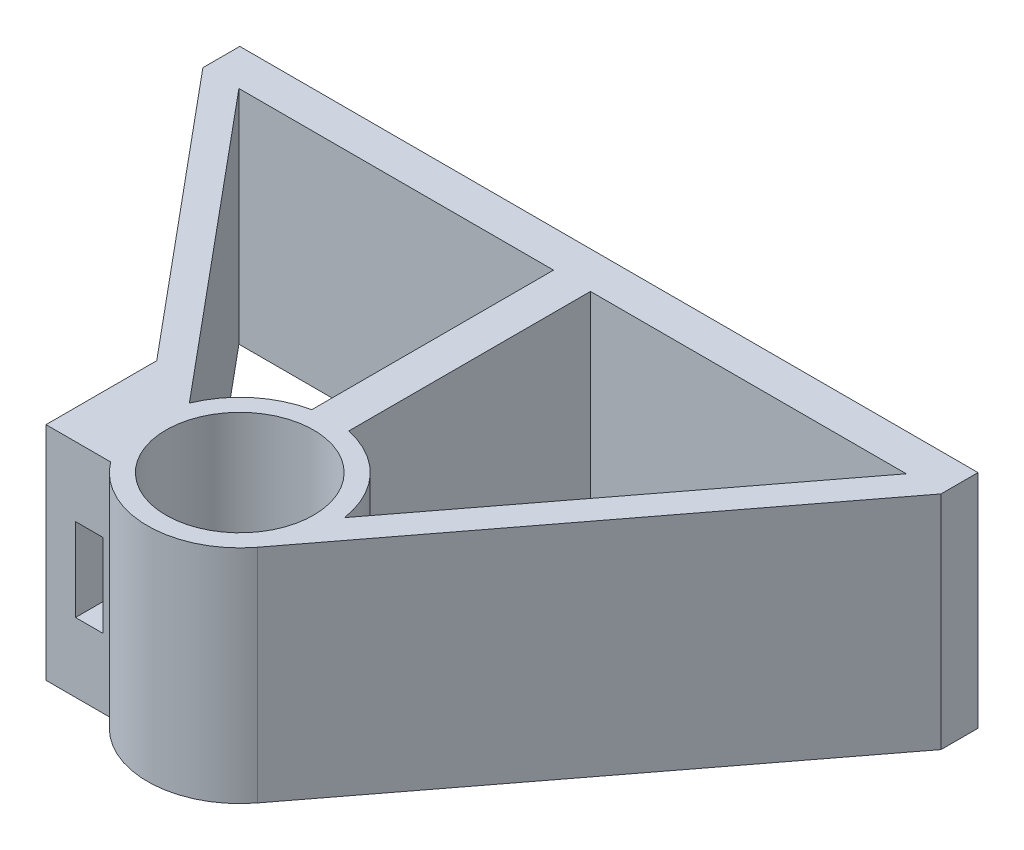
from build123d import *

# Parameters (mm, degrees)
BOSS_EXTRUDE1_DEPTH      = 6
BOSS_EXTRUDE1_DEPTH_BACK = 6
SKETCH1_R                = 4
CUT_EXTRUDE1_REACH       = 33.064
SKETCH2_W                = 1.5
SKETCH2_H                = 4.5


with BuildPart() as part:
    # Sketch1 → Boss-Extrude1 (new, two sides: drawn at the far end of the back side and taken through both)
    with BuildSketch(Plane(origin=(0, 0, 0), x_dir=(1, 0, 0), z_dir=(0, 1, 0)).offset(-BOSS_EXTRUDE1_DEPTH_BACK)):
        with BuildLine():
            Line((-7.5, 3), (-7.5, -3))
            Line((-7.5, -3), (-4, -3))
            ThreePointArc((-4, -3), (-0.01892542, -4.999964183), (3.977175044, -3.030194493))
            Line((3.977175044, -3.030194493), (20, 18))
            Line((20, 18), (20, 20))
            Line((20, 20), (-20, 20))
            Line((-20, 20), (-20, 18))
            Line((-20, 18), (-7.5, 3))
        make_face()
        Circle(SKETCH1_R, mode=Mode.SUBTRACT)
        with BuildLine():
            Line((-18.047437581, 18), (-1, 18))
            Line((-1, 18), (-1, 4.898979486))
            ThreePointArc((-1, 4.898979486), (-3.189184695, 3.850857175), (-4.626858427, 1.895305015))
            Line((-4.626858427, 1.895305015), (-18.047437581, 18))
        make_face(mode=Mode.SUBTRACT)
        with BuildLine():
            Line((1, 4.898979486), (1, 18))
            Line((1, 18), (18.114239399, 18))
            Line((18.114239399, 18), (4.948014241, 0.719134947))
            ThreePointArc((4.948014241, 0.719134947), (3.634899372, 3.433293835), (1, 4.898979486))
        make_face(mode=Mode.SUBTRACT)
    extrude(amount=BOSS_EXTRUDE1_DEPTH + BOSS_EXTRUDE1_DEPTH_BACK)

    # Sketch2 → Cut-Extrude1 (cut, up to next)
    with BuildSketch(Plane(origin=(0, 0, 3), x_dir=(-1, 0, 0), z_dir=(0, 0, -1)), mode=Mode.PRIVATE) as cut_extrude1_sk1:
        with Locations((5.15, 0)):
            Rectangle(SKETCH2_W, SKETCH2_H)
    cut_extrude1_tool1 = extrude(cut_extrude1_sk1.sketch, amount=CUT_EXTRUDE1_REACH, mode=Mode.PRIVATE) & part.part
    add(cut_extrude1_tool1.solids().sort_by_distance((-5.15, 0, 3))[0], mode=Mode.SUBTRACT)


solid = part.part
